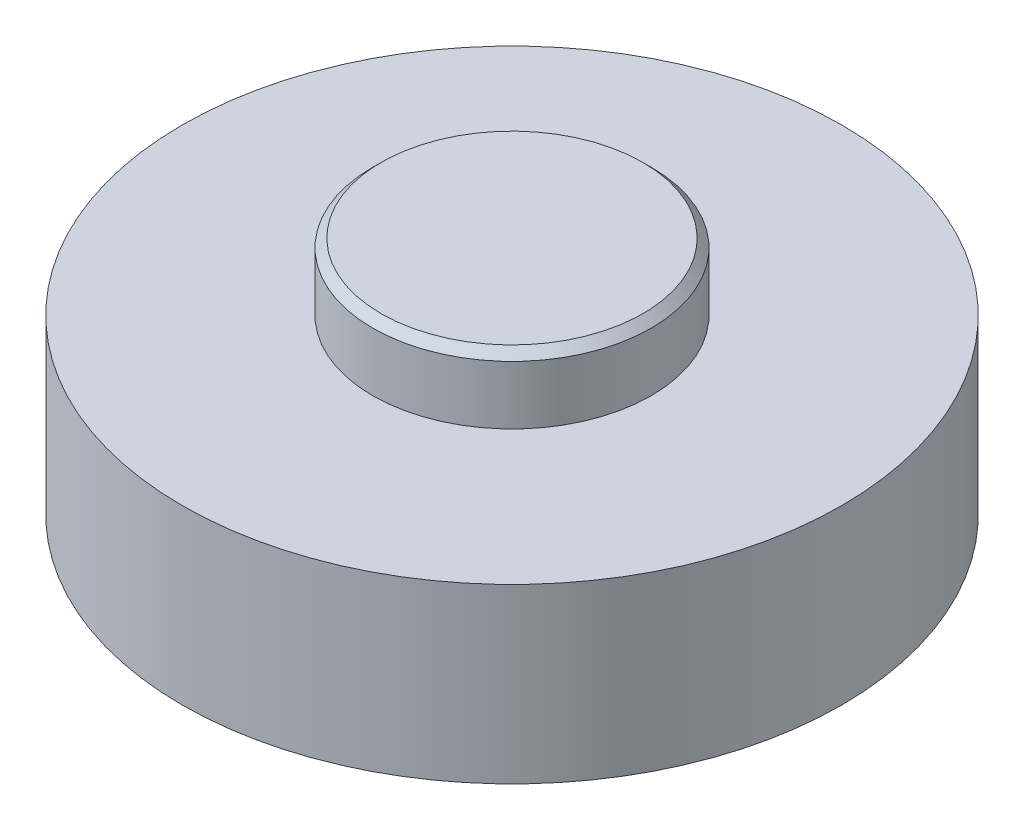
from build123d import *

# Parameters (mm, degrees)
SKETCH1_R           = 15.027499291
BOSS_EXTRUDE1_DEPTH = 6.096
SKETCH2_R           = 15.027499291
BOSS_EXTRUDE2_DEPTH = 1.778
CHAMFER1_SIZE       = 0.381
SKETCH3_R           = 6.35
BOSS_EXTRUDE3_DEPTH = 3.048
CHAMFER2_SIZE       = 0.381


with BuildPart() as part:
    # Sketch1 → Boss-Extrude1 (new body)
    with BuildSketch(Plane(origin=(0, 0, 0), x_dir=(1, 0, 0), z_dir=(0, 1, 0))):
        Circle(SKETCH1_R)
        with BuildLine():
            ThreePointArc((-9.464927768, 3.0607), (-7.033944205, 7.033944205), (-3.0607, 9.464927768))
            Line((-3.0607, 9.464927768), (-3.0607, 10.984341946))
            ThreePointArc((-3.0607, 10.984341946), (-2.896474772, 11.380816718), (-2.5, 11.545041946))
            Line((-2.5, 11.545041946), (2.5, 11.545041946))
            ThreePointArc((2.5, 11.545041946), (2.896474772, 11.380816718), (3.0607, 10.984341946))
            Line((3.0607, 10.984341946), (3.0607, 9.464927768))
            ThreePointArc((3.0607, 9.464927768), (7.033944205, 7.033944205), (9.464927768, 3.0607))
            Line((9.464927768, 3.0607), (10.984341946, 3.0607))
            ThreePointArc((10.984341946, 3.0607), (11.380816718, 2.896474772), (11.545041946, 2.5))
            Line((11.545041946, 2.5), (11.545041946, -2.5))
            ThreePointArc((11.545041946, -2.5), (11.380816718, -2.896474772), (10.984341946, -3.0607))
            Line((10.984341946, -3.0607), (9.464927768, -3.0607))
            ThreePointArc((9.464927768, -3.0607), (7.033944205, -7.033944205), (3.0607, -9.464927768))
            Line((3.0607, -9.464927768), (3.0607, -10.984341946))
            ThreePointArc((3.0607, -10.984341946), (2.896474772, -11.380816718), (2.5, -11.545041946))
            Line((2.5, -11.545041946), (-2.5, -11.545041946))
            ThreePointArc((-2.5, -11.545041946), (-2.896474772, -11.380816718), (-3.0607, -10.984341946))
            Line((-3.0607, -10.984341946), (-3.0607, -9.464927768))
            ThreePointArc((-3.0607, -9.464927768), (-7.033944205, -7.033944205), (-9.464927768, -3.0607))
            Line((-9.464927768, -3.0607), (-10.984341946, -3.0607))
            ThreePointArc((-10.984341946, -3.0607), (-11.380816718, -2.896474772), (-11.545041946, -2.5))
            Line((-11.545041946, -2.5), (-11.545041946, 2.5))
            ThreePointArc((-11.545041946, 2.5), (-11.380816718, 2.896474772), (-10.984341946, 3.0607))
            Line((-10.984341946, 3.0607), (-9.464927768, 3.0607))
        make_face(mode=Mode.SUBTRACT)
    extrude(amount=BOSS_EXTRUDE1_DEPTH)

    # Sketch2 → Boss-Extrude2 (add)
    with BuildSketch(Plane(origin=(0, 6.096, 0), x_dir=(1, 0, 0), z_dir=(0, 1, 0))):
        Circle(SKETCH2_R)
    extrude(amount=BOSS_EXTRUDE2_DEPTH)

    # Chamfer1
    chamfer1_edges = [part.edges().sort_by_distance(p)[0] for p in [
        (3.0607, 0, 10.224634857),
        (-3.0607, 0, 10.224634857),
        (2.896474772, 0, 11.380816718),
        (-2.896474772, 0, 11.380816718),
        (0, 0, 11.545041946),
        (-10.224634857, 0, 3.0607),
        (-10.224634857, 0, -3.0607),
        (-11.380816718, 0, 2.896474772),
        (-11.380816718, 0, -2.896474772),
        (-11.545041946, 0, 0),
        (-3.0607, 0, -10.224634857),
        (3.0607, 0, -10.224634857),
        (-2.896474772, 0, -11.380816718),
        (2.896474772, 0, -11.380816718),
        (0, 0, -11.545041946),
        (10.224634857, 0, -3.0607),
        (10.224634857, 0, 3.0607),
        (11.380816718, 0, -2.896474772),
        (11.380816718, 0, 2.896474772),
        (11.545041946, 0, 0),
    ]]
    chamfer(chamfer1_edges, length=CHAMFER1_SIZE)

    # Sketch3 → Boss-Extrude3 (add)
    with BuildSketch(Plane(origin=(0, 7.874, 0), x_dir=(1, 0, 0), z_dir=(0, 1, 0))):
        Circle(SKETCH3_R)
    extrude(amount=BOSS_EXTRUDE3_DEPTH)

    # Chamfer2
    chamfer2_edges = [part.edges().sort_by_distance(p)[0] for p in [
        (-6.35, 10.922, 0),
    ]]
    chamfer(chamfer2_edges, length=CHAMFER2_SIZE)


solid = part.part
